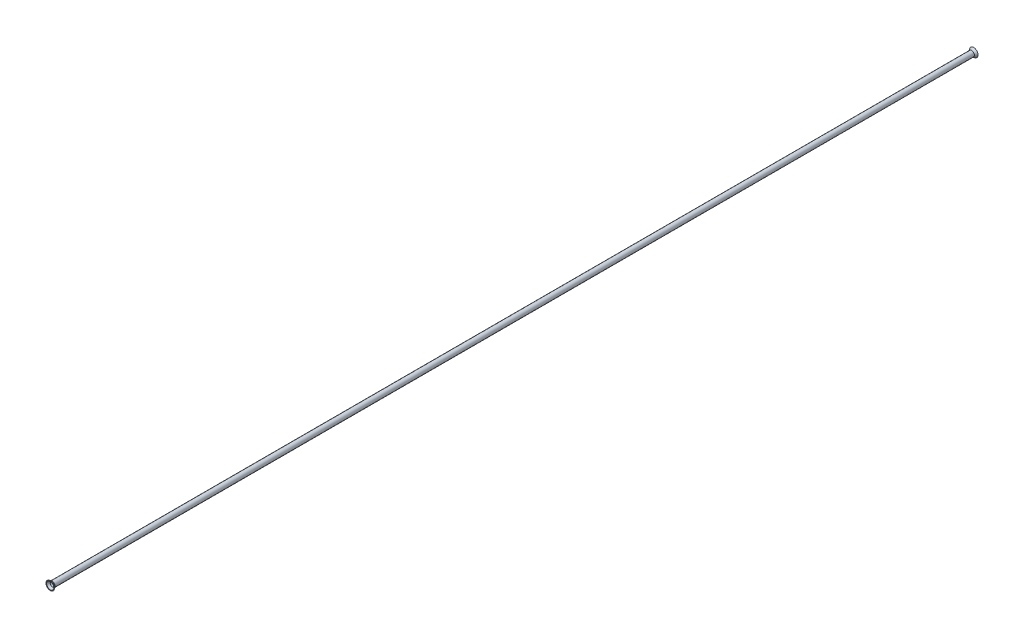
from build123d import *

# Parameters (mm, degrees)
SKETCH1_R           = 2.38125
SKETCH1_R_2         = 1.82245
BOSS_EXTRUDE1_DEPTH = 399.09877
SKETCH2_R           = 2.38125
BOSS_EXTRUDE2_DEPTH = 1.778
BOSS_EXTRUDE2_TAPER = -37
SKETCH3_R           = 1.82245
CUT_EXTRUDE1_DEPTH  = 2.7780001
CUT_EXTRUDE1_TAPER  = -37


with BuildPart() as part:
    # Sketch1 → Boss-Extrude1 (new body, symmetric)
    with BuildSketch(Plane.XY):
        Circle(SKETCH1_R)
        Circle(SKETCH1_R_2, mode=Mode.SUBTRACT)
    extrude(amount=BOSS_EXTRUDE1_DEPTH, both=True)

    # Sketch2 → Boss-Extrude2 (add)
    with BuildSketch(Plane.XY.offset(399.09877)):
        Circle(SKETCH2_R)
    boss_extrude2 = extrude(amount=BOSS_EXTRUDE2_DEPTH, taper=BOSS_EXTRUDE2_TAPER)

    # Sketch3 → Cut-Extrude1 (cut, through all)
    with BuildSketch(Plane(origin=(0, 0, 399.09877), x_dir=(-1, 0, 0), z_dir=(0, 0, -1))):
        Circle(SKETCH3_R)
    cut_extrude1 = extrude(amount=-CUT_EXTRUDE1_DEPTH, taper=CUT_EXTRUDE1_TAPER, mode=Mode.SUBTRACT)

    # Mirror1: Boss-Extrude2, Cut-Extrude1 across plane
    add(boss_extrude2.mirror(Plane.XY))
    add(cut_extrude1.mirror(Plane.XY), mode=Mode.SUBTRACT)


solid = part.part
